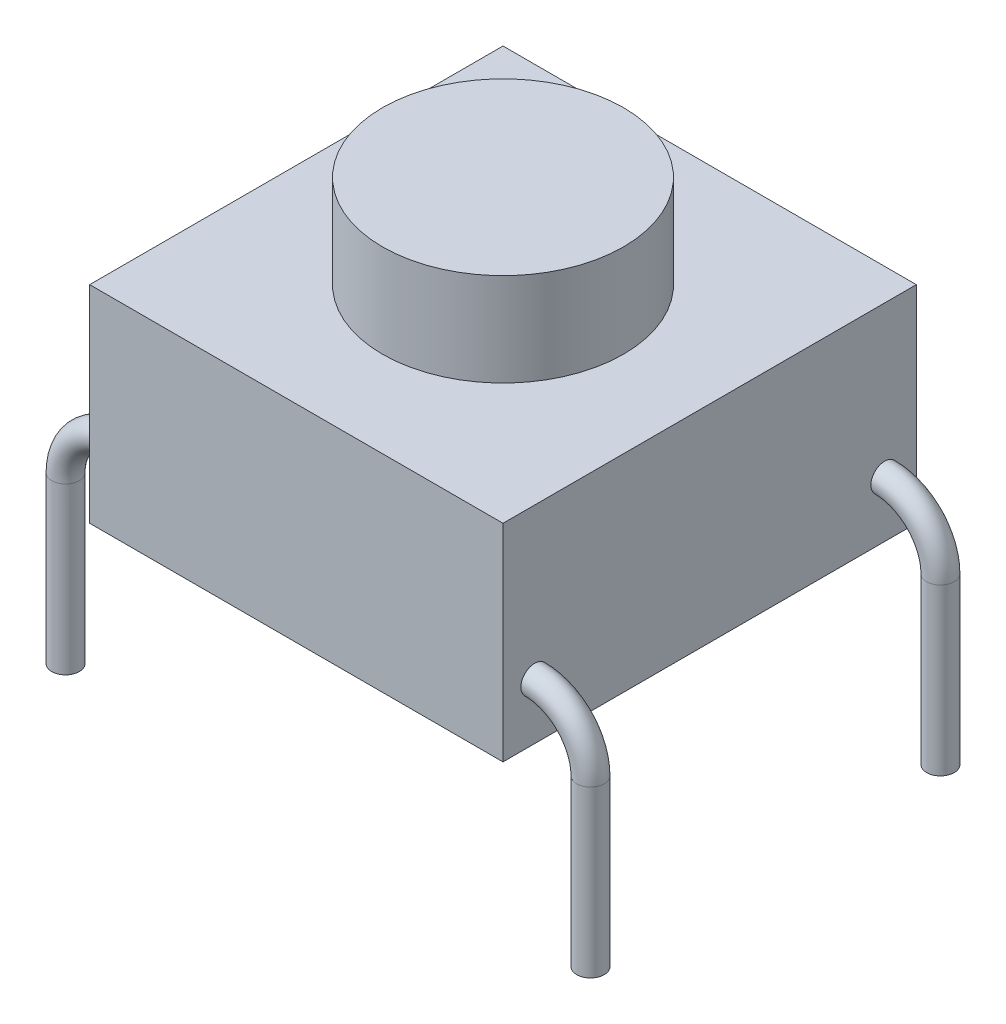
from build123d import *

# Parameters (mm, degrees)
SKETCH1_W                                  = 6
SKETCH1_H                                  = 6
BOSS_EXTRUDE1_DEPTH                        = 3
SKETCH2_R                                  = 1.75
BOSS_EXTRUDE2_DEPTH                        = 1.35
SKETCH3_R                                  = 0.2
BOSS_EXTRUDE3_DEPTH                        = 2.4
BOSS_EXTRUDE3_2_DEPTH                      = 2.4
BOSS_EXTRUDE3_3_DEPTH                      = 2.4
BOSS_EXTRUDE3_4_DEPTH                      = 2.4
SWEEP1_PROFILE_R                           = 0.2
MIRROR1_AT_THE_SECOND_PLANE_COPY_1_SKETC_R = 0.2


with BuildPart() as part:
    # Sketch1 → Boss-Extrude1 (new body)
    with BuildSketch(Plane(origin=(0, 0, 0), x_dir=(1, 0, 0), z_dir=(0, 1, 0))):
        Rectangle(SKETCH1_W, SKETCH1_H)
    extrude(amount=BOSS_EXTRUDE1_DEPTH)

    # Sketch2 → Boss-Extrude2 (add)
    with BuildSketch(Plane(origin=(0, 3, 0), x_dir=(1, 0, 0), z_dir=(0, 1, 0))):
        Circle(SKETCH2_R)
    extrude(amount=BOSS_EXTRUDE2_DEPTH)



with BuildPart() as body_2:
    # Sketch3 → Boss-Extrude3 (new body)
    with BuildSketch(Plane.XZ):
        with Locations((-3.81, 2.54)):
            Circle(SKETCH3_R)
    extrude(amount=BOSS_EXTRUDE3_DEPTH)


with BuildPart() as body_3:
    # Sketch3 → Boss-Extrude3 2 (new body)
    with BuildSketch(Plane.XZ):
        with Locations((3.81, 2.54)):
            Circle(SKETCH3_R)
    extrude(amount=BOSS_EXTRUDE3_2_DEPTH)


with BuildPart() as body_4:
    # Sketch3 → Boss-Extrude3 3 (new body)
    with BuildSketch(Plane.XZ):
        with Locations((3.81, -2.54)):
            Circle(SKETCH3_R)
    extrude(amount=BOSS_EXTRUDE3_3_DEPTH)


with BuildPart() as body_5:
    # Sketch3 → Boss-Extrude3 4 (new body)
    with BuildSketch(Plane.XZ):
        with Locations((-3.81, -2.54)):
            Circle(SKETCH3_R)
    extrude(amount=BOSS_EXTRUDE3_4_DEPTH)


with BuildPart() as part_1:
    add(part.part)

    add(body_2.part)  # Sweep1 merges body 2
    # Sweep1: sweep along a path in Sketch4
    with BuildLine(Plane.XY.offset(2.54)) as sweep1_path:
        ThreePointArc((-3.81, 0), (-3.572756493, 0.572756493), (-3, 0.81))
    # Sweep1 profile (on start of the path) → Sweep1 (sweep)
    with BuildSketch(Plane(origin=(-3.81, 0, 2.54), x_dir=(1, 0, 0), z_dir=(0, 1, 0))):
        Circle(SWEEP1_PROFILE_R)
    sweep1 = sweep(path=sweep1_path.line)

    # Mirror1: Sweep1 across plane
    add(sweep1.mirror(Plane(origin=(0, 0, 0), x_dir=(0, 0, 1), z_dir=(1, 0, 0))))

    # Mirror1 at the second plane: Sweep1 across plane
    add(sweep1.mirror(Plane.XY))

    # Mirror1 at the second plane copy 1: sweep along a path in Mirror1 at the second plane copy 1 path
    with BuildLine(Plane(origin=(0, 0, -2.54), x_dir=(-1, 0, 0), z_dir=(0, 0, -1))) as mirror1_at_the_second_plane_copy_1_path:
        ThreePointArc((-3.81, 0), (-3.572756493, 0.572756493), (-3, 0.81))
    # Mirror1 at the second plane copy 1 sketc → Mirror1 at the second plane copy 1 (sweep)
    with BuildSketch(Plane(origin=(3.81, 0, -2.54), x_dir=(-1, 0, 0), z_dir=(0, 1, 0))):
        Circle(MIRROR1_AT_THE_SECOND_PLANE_COPY_1_SKETC_R)
    sweep(path=mirror1_at_the_second_plane_copy_1_path.line)


solid = Compound([body_3.part, body_4.part, body_5.part, part_1.part])
